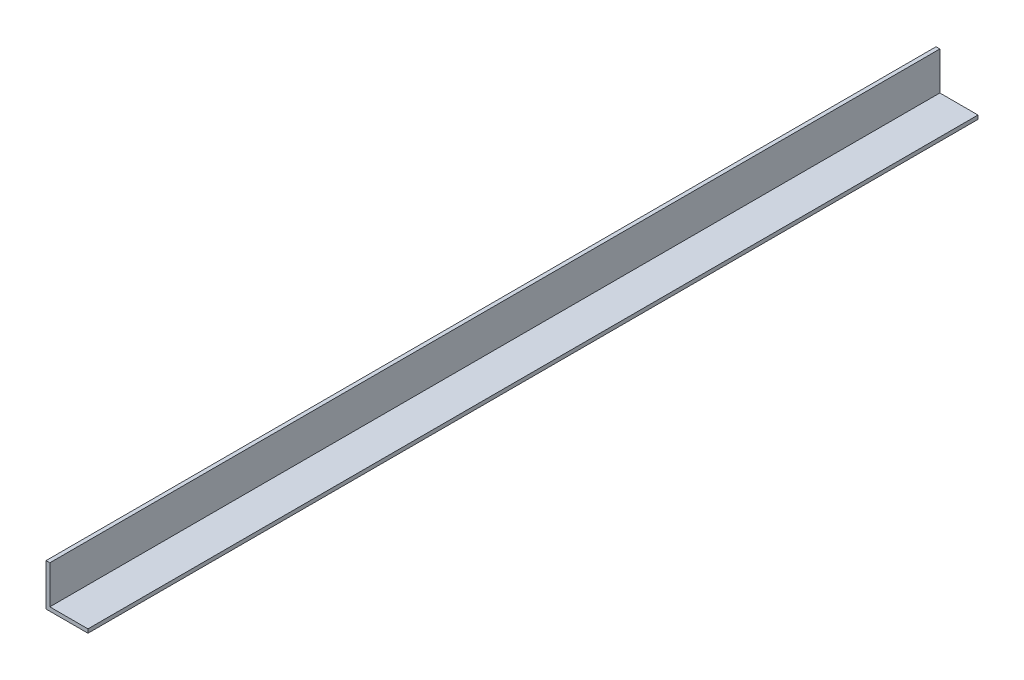
from build123d import *

# Parameters (mm, degrees)
EXTRUDE_1_DEPTH = 700


with BuildPart() as part:
    # Эскиз1 → Вытянуть-Тонкостенный1 (new body)
    with BuildSketch(Plane.XY):
        Polygon((0, 30), (0, 0), (30, 0), (30, -3), (-3, -3), (-3, 30), align=None)
    extrude(amount=EXTRUDE_1_DEPTH)


solid = part.part
